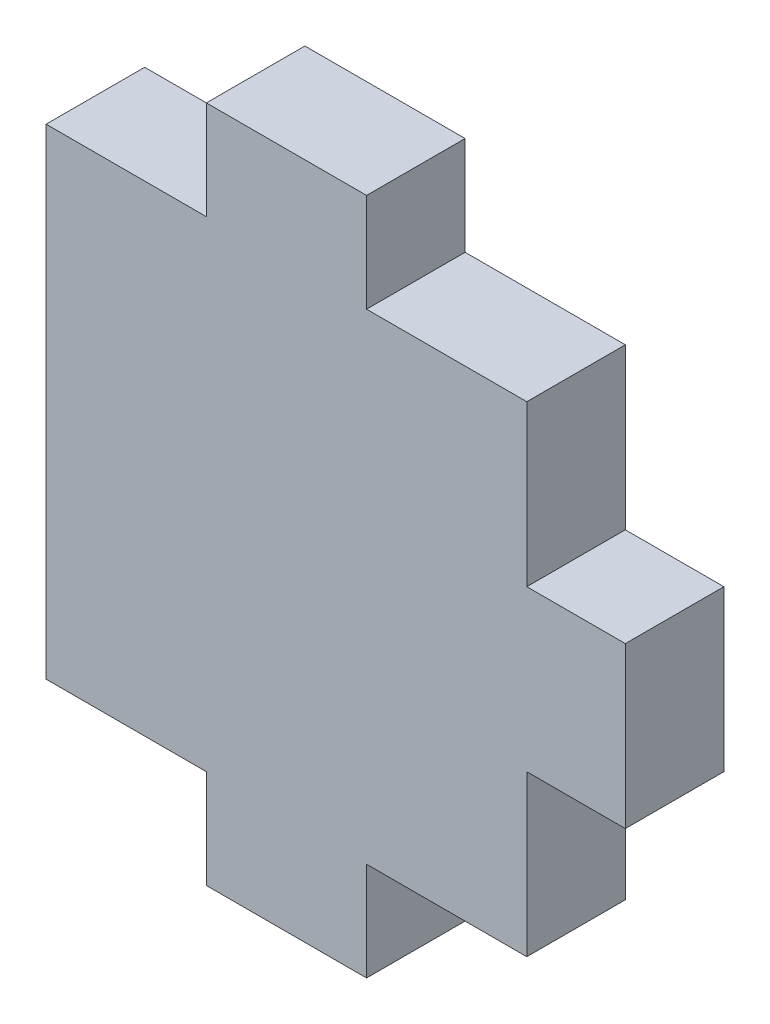
from build123d import *

# Parameters (mm, degrees)
BOSS_EXTRUDE1_DEPTH = 5.207


with BuildPart() as part:
    # Sketch1 → Boss-Extrude1 (new body)
    with BuildSketch(Plane.XY):
        Polygon((10.786148393, 17.505366953), (19.25281506, 17.505366953), (19.25281506, 9.038700286), (24.45981506, 9.038700286), (24.45981506, 0.572033619), (19.25281506, 0.572033619), (19.25281506, -7.894633047), (10.786148393, -7.894633047), (10.786148393, -13.101633047), (2.319481726, -13.101633047), (2.319481726, -7.894633047), (-6.14718494, -7.894633047), (-6.14718494, 17.505366953), (2.319481726, 17.505366953), (2.319481726, 22.712366953), (10.786148393, 22.712366953), align=None)
    extrude(amount=BOSS_EXTRUDE1_DEPTH)


solid = part.part
